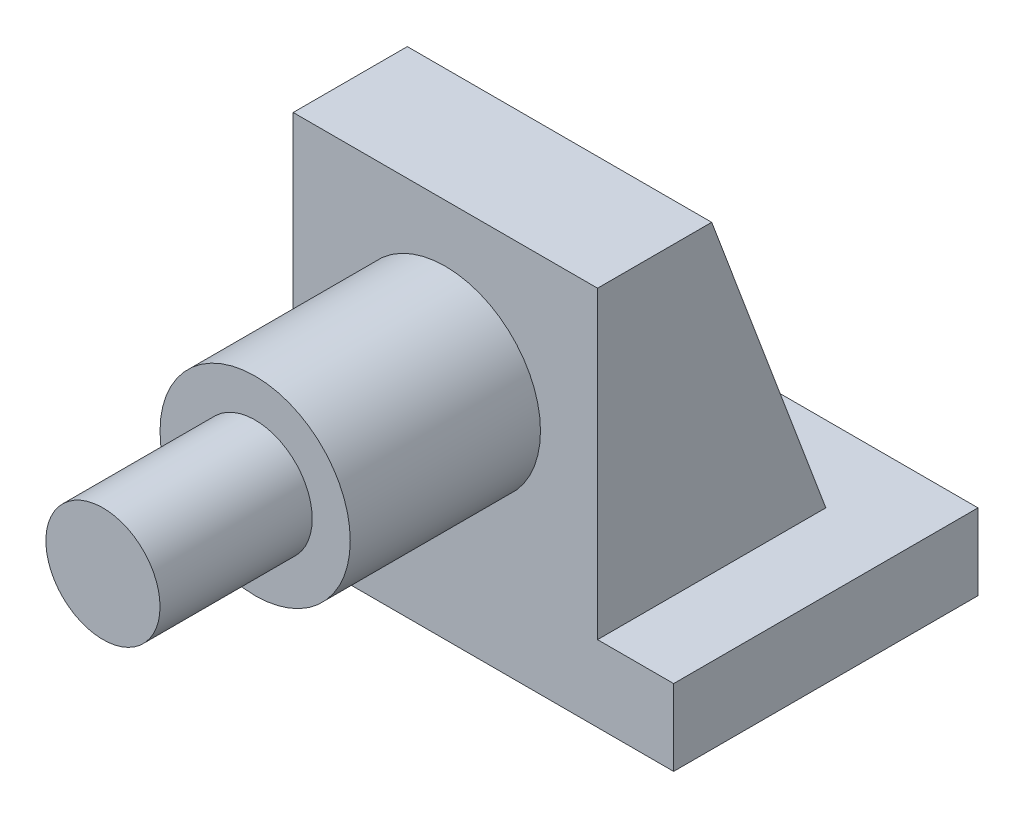
from build123d import *

# Parameters (mm, degrees)
EXTRUDE_1_DEPTH     = 40
CUT_EXTRUDE_1_DEPTH = 40
SKETCH_3_R          = 12.5
EXTRUDE_2_DEPTH     = 25
SKETCH_4_R          = 7.5
EXTRUDE_3_DEPTH     = 20


with BuildPart() as part:
    # 草图1 → 凸台-拉伸1 (new body)
    with BuildSketch(Plane.XY):
        Polygon((-20, -20), (-30, -20), (-30, -30), (30, -30), (30, -20), (20, -20), (20, 20), (-20, 20), align=None)
    extrude(amount=EXTRUDE_1_DEPTH)

    # 草图2 → 切除-拉伸1 (cut)
    with BuildSketch(Plane(origin=(20, 0, 0), x_dir=(0, 0, -1), z_dir=(1, 0, 0))):
        Polygon((0, -20), (-10, -20), (-25, 20), (0, 20), align=None)
    extrude(amount=-CUT_EXTRUDE_1_DEPTH, mode=Mode.SUBTRACT)

    # 草图3 → 凸台-拉伸2 (add)
    with BuildSketch(Plane.XY.offset(40)):
        Circle(SKETCH_3_R)
    extrude(amount=EXTRUDE_2_DEPTH)

    # 草图4 → 凸台-拉伸3 (add)
    with BuildSketch(Plane.XY.offset(65)):
        Circle(SKETCH_4_R)
    extrude(amount=EXTRUDE_3_DEPTH)


solid = part.part
